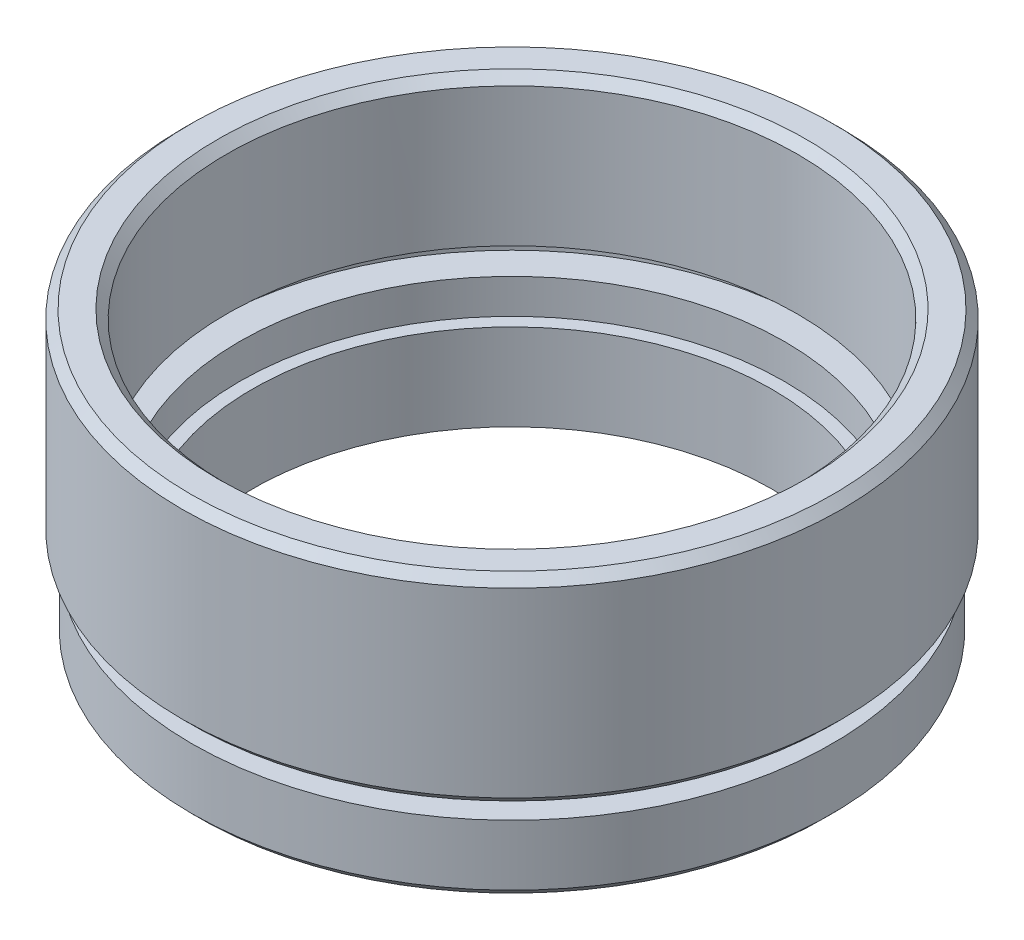
from build123d import *

# Parameters (mm, degrees)
CHAMFER_1_SIZE = 0.5


with BuildPart() as part:
    # 草图1 → 旋转1 (revolve)
    with BuildSketch(Plane.XY, mode=Mode.PRIVATE) as revolve_1_sk:
        Polygon((15, 0), (18.5, 0), (18.5, 4), (17, 4), (17, 5), (19.05, 5), (19.05, 16.5), (16.5, 16.5), (16.5, 8), (17.6, 8), (17.6, 7), (15.75, 7), (15.75, 5), (15, 5), align=None)
    revolve(revolve_1_sk.sketch.rotate(Axis((0, 0, 0), (0, 1, 0)), 90), axis=Axis((0, 0, 0), (0, 1, 0)))  # turned: the seam where the file's is

    # 倒角1
    chamfer_1_edges = [part.edges().sort_by_distance(p)[0] for p in [
        (0, 16.5, 16.5),
        (0, 16.5, 19.05),
        (0, 5, 19.05),
        (0, 0, 18.5),
    ]]
    chamfer(chamfer_1_edges, length=CHAMFER_1_SIZE)


solid = part.part
